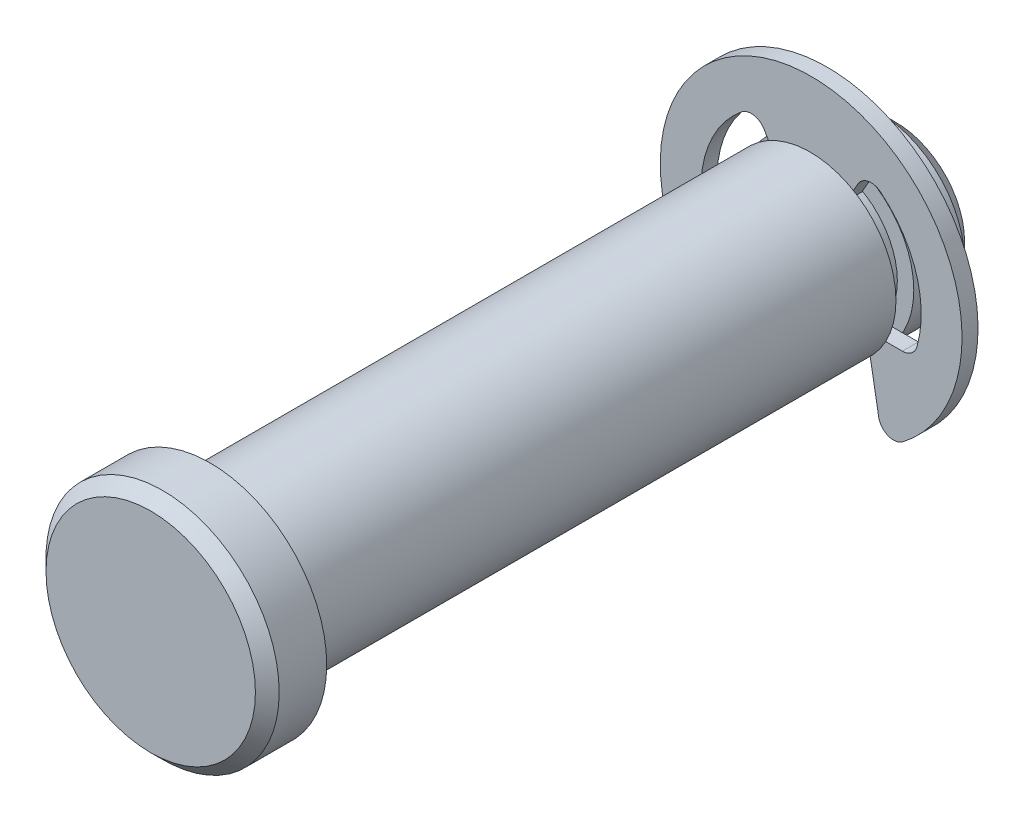
from build123d import *

# Parameters (mm, degrees)
SKETCH2_R      = 4.7625
EXTRUDE1_DEPTH = 19.05
SKETCH3_W      = 0.9906
SKETCH3_H      = 0.9144
SKETCH8_R      = 6.477
EXTRUDE6_DEPTH = 3.302
CHAMFER2_SIZE  = 0.6604
SKETCH4_R      = 8.382
SKETCH4_R_2    = 3.8481
EXTRUDE2_DEPTH = 0.4445
EXTRUDE4_DEPTH = 20.05
EXTRUDE5_DEPTH = 0.889
FILLET1_R      = 0.8382
CHAMFER1_SIZE  = 0.9525


with BuildPart() as part:
    # Sketch2 → Extrude1 (new body, symmetric)
    with BuildSketch(Plane.XY):
        Circle(SKETCH2_R)
    extrude(amount=EXTRUDE1_DEPTH, both=True)

    # Sketch3 → Cut-Revolve1 (revolve, cut)
    with BuildSketch(Plane(origin=(0, 0, 0), x_dir=(0, 0, -1), z_dir=(1, 0, 0))):
        with Locations((14.7828, 4.3053)):
            Rectangle(SKETCH3_W, SKETCH3_H)
    revolve(axis=Axis((0, 0, 19.05), (0, 0, -1)), mode=Mode.SUBTRACT)

    # Sketch8 → Extrude6 (add)
    with BuildSketch(Plane.XY.offset(19.05)):
        Circle(SKETCH8_R)
    extrude(amount=EXTRUDE6_DEPTH)

    # Chamfer2
    chamfer2_edges = [part.edges().sort_by_distance(p)[0] for p in [
        (-6.477, 0, 22.352),
    ]]
    chamfer(chamfer2_edges, length=CHAMFER2_SIZE)

    # Chamfer1
    chamfer1_edges = [part.edges().sort_by_distance(p)[0] for p in [
        (-4.7625, 0, -19.05),
    ]]
    chamfer(chamfer1_edges, length=CHAMFER1_SIZE)


with BuildPart() as body_2:
    # Sketch4 → Extrude2 (new body, symmetric)
    with BuildSketch(Plane.XY.offset(-14.7828)):
        Circle(SKETCH4_R)
        Circle(SKETCH4_R_2, mode=Mode.SUBTRACT)
    extrude(amount=EXTRUDE2_DEPTH, both=True)

    # Sketch5 → Extrude4 (cut, through all)
    with BuildSketch(Plane.XY):
        with BuildLine():
            Line((-3.057525, 5.295788645), (0, 0))
            Line((0, 0), (3.057525, 5.295788645))
            ThreePointArc((3.057525, 5.295788645), (5.785069674, 1.981616859), (5.662420154, -2.30886))
            Line((5.662420154, -2.30886), (3.07848, -2.30886))
            Line((3.07848, -2.30886), (3.972784338, -7.380711931))
            ThreePointArc((3.972784338, -7.380711931), (0, -8.382), (-3.972784338, -7.380711931))
            Line((-3.972784338, -7.380711931), (-3.07848, -2.30886))
            Line((-3.07848, -2.30886), (-5.662420154, -2.30886))
            ThreePointArc((-5.662420154, -2.30886), (-5.785069674, 1.981616859), (-3.057525, 5.295788645))
        make_face()
    extrude(amount=-EXTRUDE4_DEPTH, mode=Mode.SUBTRACT)

    # Sketch6 → Extrude5 (add)
    with BuildSketch(Plane.XY.offset(-14.3383)):
        with BuildLine():
            Line((-1.92405, 3.332552356), (1.92405, 3.332552356))
            ThreePointArc((1.92405, 3.332552356), (0, 3.8481), (-1.92405, 3.332552356))
        make_face()
    extrude(amount=-EXTRUDE5_DEPTH)

    # Fillet1
    fillet1_edges = [body_2.edges().sort_by_distance(p)[0] for p in [
        (3.057525, 5.295788645, -14.7828),
        (3.972784338, -7.380711931, -14.7828),
        (-5.662420154, -2.30886, -14.7828),
        (5.662420154, -2.30886, -14.7828),
        (-3.972784338, -7.380711931, -14.7828),
        (-3.057525, 5.295788645, -14.7828),
    ]]
    fillet(fillet1_edges, radius=FILLET1_R)


solid = Compound([part.part, body_2.part])
